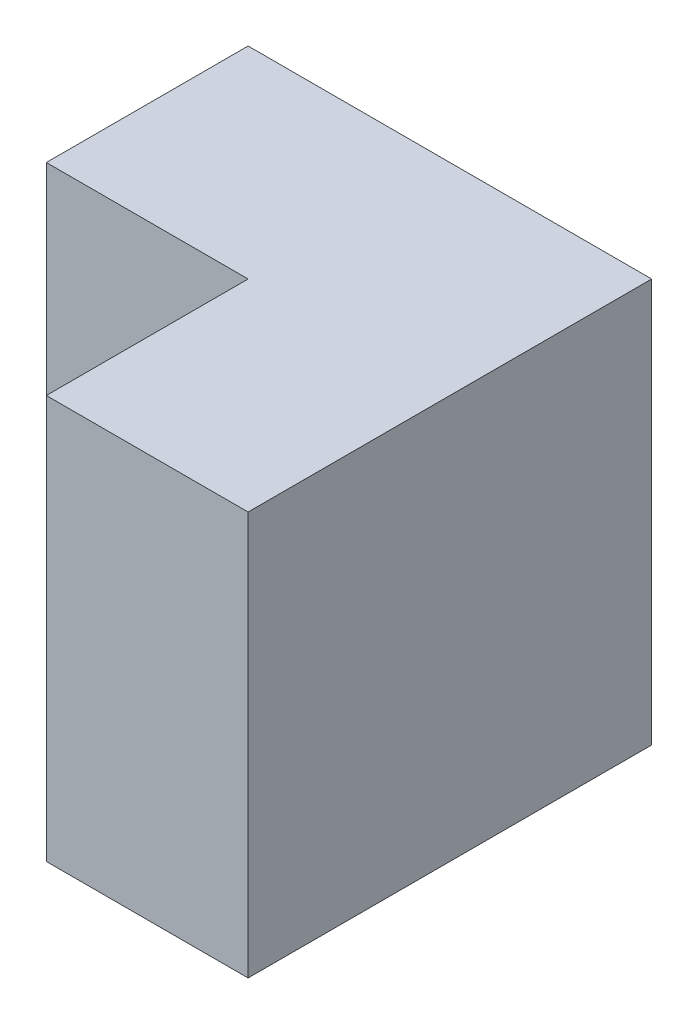
from build123d import *

# Parameters (mm, degrees)
SKETCH3_W           = 20
SKETCH3_H           = 20
BOSS_EXTRUDE1_DEPTH = 20
SKETCH4_W           = 10
SKETCH4_H           = 20
CUT_EXTRUDE1_DEPTH  = 10


with BuildPart() as part:
    # Sketch3 → Boss-Extrude1 (new body)
    with BuildSketch(Plane.XY):
        with Locations((10, 10)):
            Rectangle(SKETCH3_W, SKETCH3_H)
    extrude(amount=BOSS_EXTRUDE1_DEPTH)

    # Sketch4 → Cut-Extrude1 (cut)
    with BuildSketch(Plane.XY.offset(20)):
        with Locations((5, 10)):
            Rectangle(SKETCH4_W, SKETCH4_H)
    extrude(amount=-CUT_EXTRUDE1_DEPTH, mode=Mode.SUBTRACT)


solid = part.part
